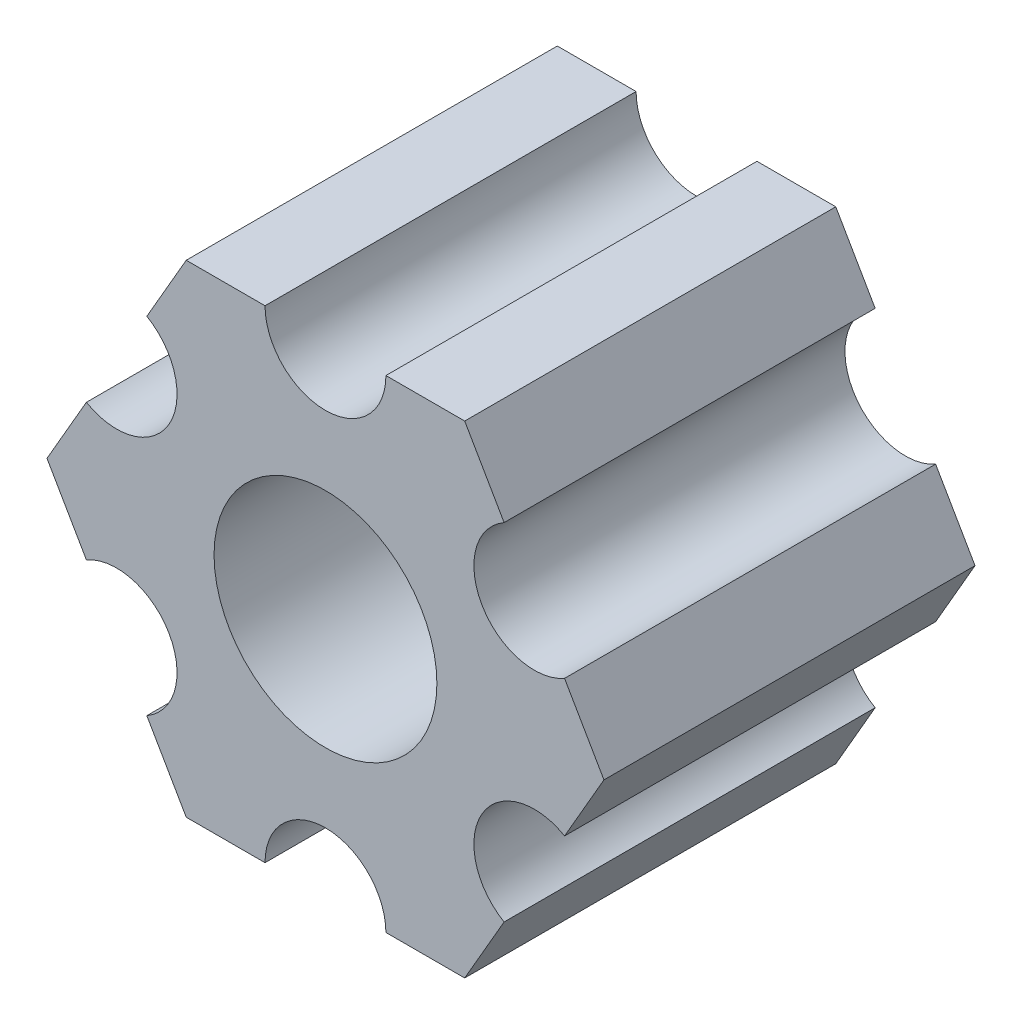
from build123d import *

# Parameters (mm, degrees)
SKETCH1_R           = 2.9337
BOSS_EXTRUDE1_DEPTH = 9.77


with BuildPart() as part:
    # Sketch1 → Boss-Extrude1 (new body)
    with BuildSketch(Plane(origin=(0, 0, 0), x_dir=(-1, 0, 0), z_dir=(0, 0, -1))):
        with BuildLine():
            Line((-4.703606334, -4.55311485), (-3.666174209, -6.35))
            Line((-3.666174209, -6.35), (-1.591309959, -6.35))
            ThreePointArc((-1.591309959, -6.35), (0, -4.758690041), (1.591309959, -6.35))
            Line((1.591309959, -6.35), (3.666174209, -6.35))
            Line((3.666174209, -6.35), (4.703606334, -4.55311485))
            ThreePointArc((4.703606334, -4.55311485), (4.121146464, -2.37934502), (6.294916294, -1.79688515))
            Line((6.294916294, -1.79688515), (7.332348419, 0))
            Line((7.332348419, 0), (6.294916294, 1.79688515))
            ThreePointArc((6.294916294, 1.79688515), (4.121146464, 2.37934502), (4.703606334, 4.55311485))
            Line((4.703606334, 4.55311485), (3.666174209, 6.35))
            Line((3.666174209, 6.35), (1.591309959, 6.35))
            ThreePointArc((1.591309959, 6.35), (0, 4.758690041), (-1.591309959, 6.35))
            Line((-1.591309959, 6.35), (-3.666174209, 6.35))
            Line((-3.666174209, 6.35), (-4.703606334, 4.55311485))
            ThreePointArc((-4.703606334, 4.55311485), (-4.121146464, 2.37934502), (-6.294916294, 1.79688515))
            Line((-6.294916294, 1.79688515), (-7.332348419, 0))
            Line((-7.332348419, 0), (-6.294916294, -1.79688515))
            ThreePointArc((-6.294916294, -1.79688515), (-4.121146464, -2.37934502), (-4.703606334, -4.55311485))
        make_face()
        Circle(SKETCH1_R, mode=Mode.SUBTRACT)
    extrude(amount=-BOSS_EXTRUDE1_DEPTH)


solid = part.part
